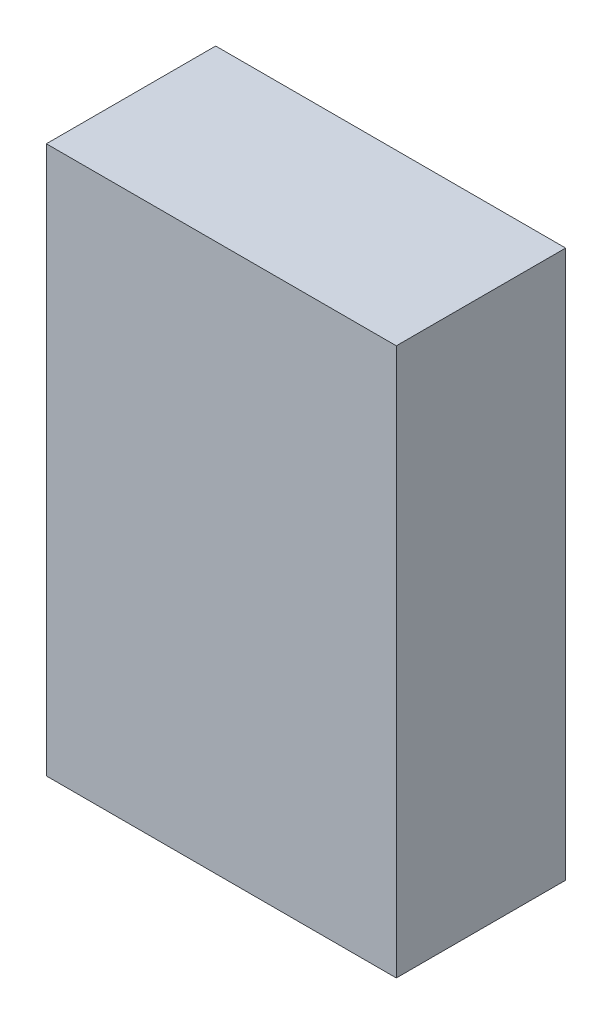
from build123d import *

# Parameters (mm, degrees)
ESQUISSE2_W        = 62
ESQUISSE2_H        = 97
BOSS_EXTRU_1_DEPTH = 30


with BuildPart() as part:
    # Esquisse2 → Boss.-Extru.1 (new body)
    with BuildSketch(Plane.XY):
        Rectangle(ESQUISSE2_W, ESQUISSE2_H)
    extrude(amount=BOSS_EXTRU_1_DEPTH)


solid = part.part
